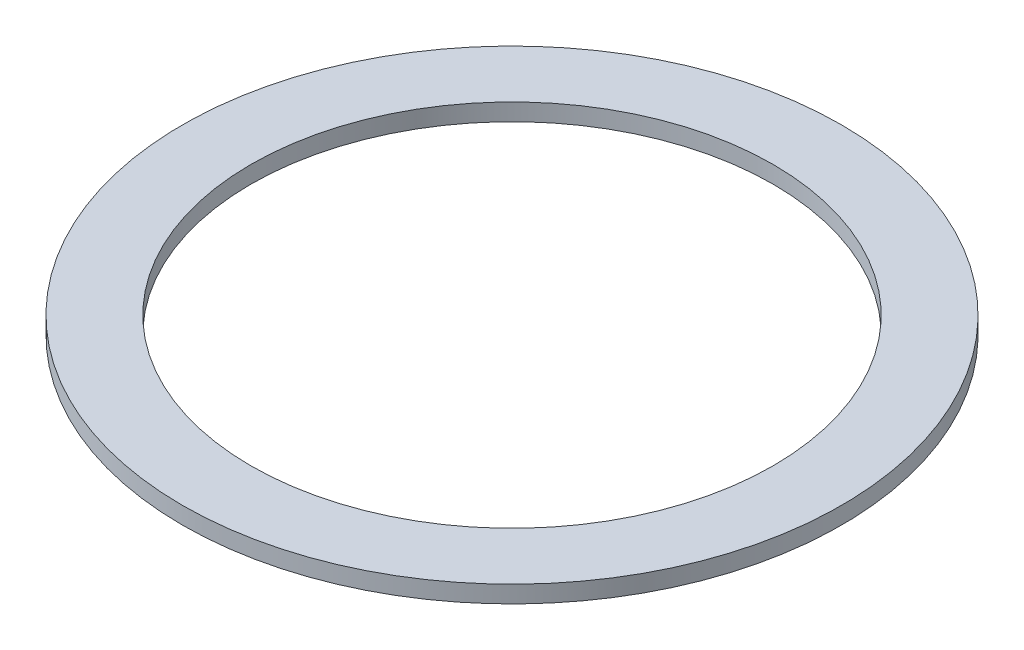
from build123d import *

# Parameters (mm, degrees)
SKETCH1_R           = 19.25
SKETCH1_R_2         = 15.25
BOSS_EXTRUDE1_DEPTH = 1


with BuildPart() as part:
    # Sketch1 → Boss-Extrude1 (new body)
    with BuildSketch(Plane(origin=(0, 0, 0), x_dir=(1, 0, 0), z_dir=(0, 1, 0))):
        Circle(SKETCH1_R)
        Circle(SKETCH1_R_2, mode=Mode.SUBTRACT)
    extrude(amount=BOSS_EXTRUDE1_DEPTH)


solid = part.part
